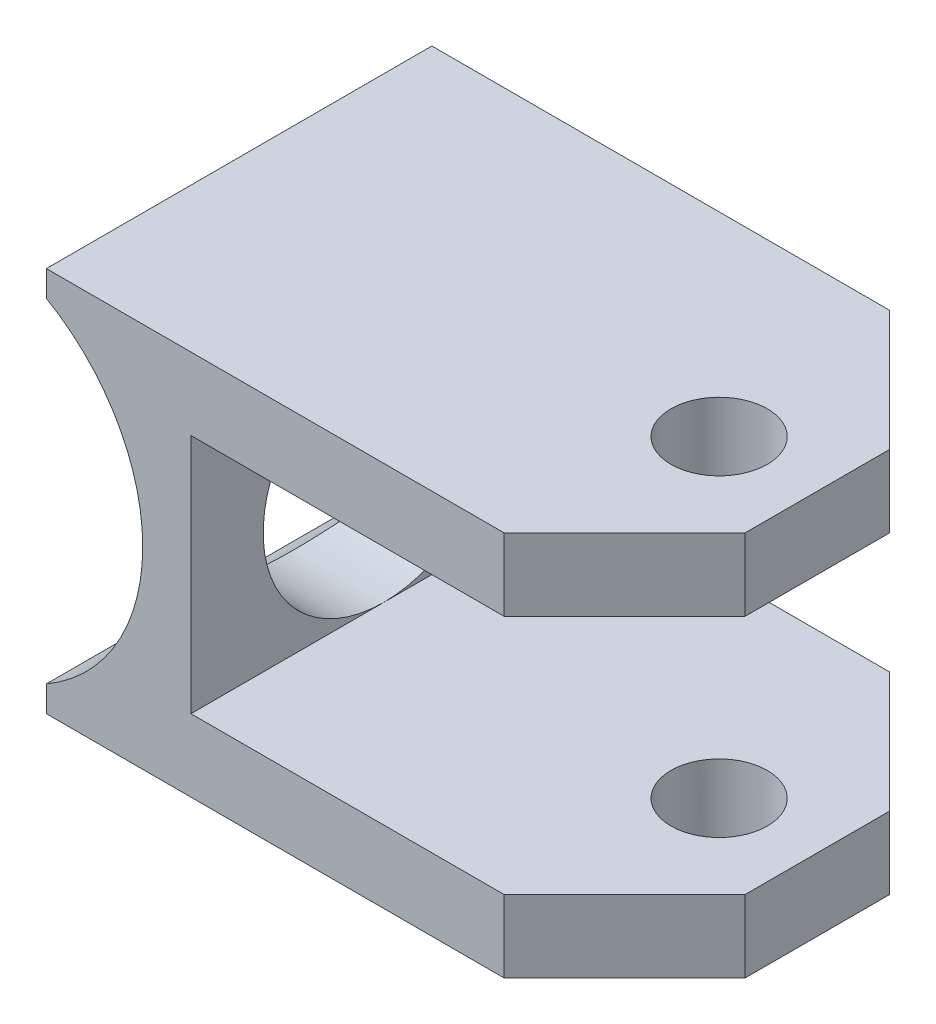
from build123d import *

# Parameters (mm, degrees)
BOSS_EXTRUDE1_DEPTH         = 25.4
F_1_4_0_25_DIAMETER_HOLE1_D = 6.35
CHAMFER1_SIZE               = 7.9375
SKETCH6_R                   = 7.9375
CUT_EXTRUDE1_DEPTH          = 10.525


with BuildPart() as part:
    # Sketch1 → Boss-Extrude1 (new body)
    with BuildSketch(Plane.XY):
        with BuildLine():
            Line((6.35, 12.7), (44.45, 12.7))
            Line((44.45, 12.7), (44.45, 7.9375))
            Line((44.45, 7.9375), (15.875, 7.9375))
            Line((15.875, 7.9375), (15.875, -7.9375))
            Line((15.875, -7.9375), (44.45, -7.9375))
            Line((44.45, -7.9375), (44.45, -12.7))
            Line((44.45, -12.7), (6.35, -12.7))
            Line((6.35, -12.7), (6.35, -10.998522628))
            ThreePointArc((6.35, -10.998522628), (12.7, 0), (6.35, 10.998522628))
            Line((6.35, 10.998522628), (6.35, 12.7))
        make_face()
    extrude(amount=BOSS_EXTRUDE1_DEPTH)

    # 1/4 (0.25) Diameter Hole1 (through all)
    with Locations(Plane(origin=(0, 12.7, 0), x_dir=(1, 0, 0), z_dir=(0, 1, 0))):
        with Locations((38.1, -12.821774192)):
            Hole(F_1_4_0_25_DIAMETER_HOLE1_D / 2)

    # Chamfer1
    chamfer1_edges = [part.edges().sort_by_distance(p)[0] for p in [
        (44.45, 10.31875, 0),
        (44.45, 10.31875, 25.4),
        (44.45, -10.31875, 25.4),
        (44.45, -10.31875, 0),
    ]]
    chamfer(chamfer1_edges, length=CHAMFER1_SIZE)

    # Sketch6 → Cut-Extrude1 (cut, through all)
    with BuildSketch(Plane(origin=(15.875, 0, 0), x_dir=(0, 0, -1), z_dir=(1, 0, 0))):
        with Locations((-12.7, 0)):
            Circle(SKETCH6_R)
    extrude(amount=-CUT_EXTRUDE1_DEPTH, mode=Mode.SUBTRACT)


solid = part.part
